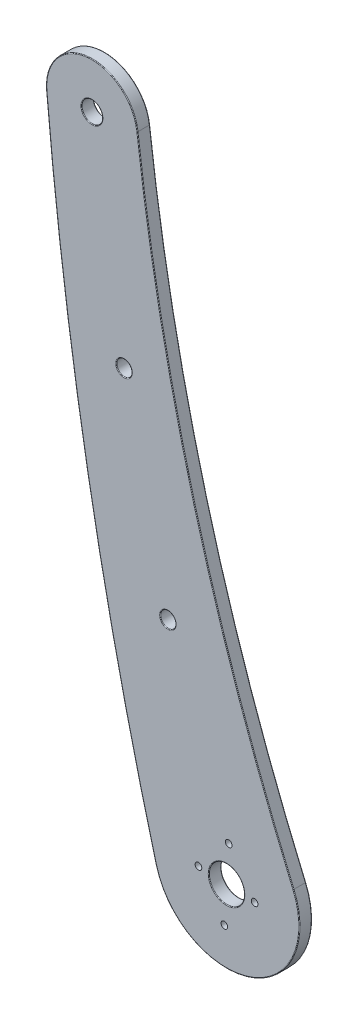
from build123d import *

# Parameters (mm, degrees)
SKETCH1_R              = 2.5
SKETCH1_R_2            = 4.25
BOSS_EXTRUDE1_DEPTH    = 3
M3_5_CLEARANCE_HOLE2_D = 3.7
FILLET1_R              = 0.15
SKETCH5_R              = 0.8
CUT_EXTRUDE1_DEPTH     = 10


with BuildPart() as part:
    # Sketch1 → Boss-Extrude1 (new body)
    with BuildSketch(Plane.XY):
        with BuildLine():
            ThreePointArc((-41.610876402, 203.318893996), (-27.897661437, 132.566736908), (-4.155361538, 64.520993523))
            ThreePointArc((-4.155361538, 64.520993523), (-14.44377014, 41.06076368), (-37.109507396, 52.998020086))
            ThreePointArc((-37.109507396, 52.998020086), (-53.580358622, 126.437133771), (-63.490331164, 201.045342457))
            ThreePointArc((-63.490331164, 201.045342457), (-53.669587691, 212.950626168), (-41.610876402, 203.318893996))
        make_face()
        with Locations((-52.532670476, 202.009537592)):
            Circle(SKETCH1_R, mode=Mode.SUBTRACT)
        with Locations((-20.22, 57.58)):
            Circle(SKETCH1_R_2, mode=Mode.SUBTRACT)
    extrude(amount=-BOSS_EXTRUDE1_DEPTH)

    # M3.5 Clearance Hole2 (through all)
    with Locations(Plane(origin=(0, 0, -3), x_dir=(-1, 0, 0), z_dir=(0, 0, -1))):
        with Locations((44.832747943, 152.605983135), (34.306162612, 105.554785282)):
            Hole(M3_5_CLEARANCE_HOLE2_D / 2)

    # Fillet1
    fillet1_edges = [part.edges().sort_by_distance(p)[0] for p in [
        (-55.032670476, 202.009537592, -3),
        (-55.032670476, 202.009537592, 0),
        (-14.44377014, 41.06076368, -3),
        (-24.47, 57.58, -3),
        (-24.47, 57.58, 0),
        (-27.897661437, 132.566736908, -3),
        (-36.156162612, 105.554785282, -3),
        (-36.156162612, 105.554785282, 0),
        (-46.682747943, 152.605983135, -3),
        (-46.682747943, 152.605983135, 0),
        (-53.669587691, 212.950626168, -3),
        (-27.897661437, 132.566736908, 0),
        (-14.44377014, 41.06076368, 0),
        (-53.580358622, 126.437133771, 0),
        (-53.669587691, 212.950626168, 0),
        (-53.580358622, 126.437133771, -3),
    ]]
    fillet(fillet1_edges, radius=FILLET1_R)

    # Sketch5 → Cut-Extrude1 (cut)
    with BuildSketch(Plane(origin=(0, 0, -3), x_dir=(-1, 0, 0), z_dir=(0, 0, -1))):
        with Locations((26.957856554, 57.984708606)):
            Circle(SKETCH5_R)
        with Locations((20.744622268, 48.845741504)):
            Circle(SKETCH5_R)
        with Locations((13.482143446, 57.175291394)):
            Circle(SKETCH5_R)
        with Locations((19.695377732, 66.314258496)):
            Circle(SKETCH5_R)
    extrude(amount=-CUT_EXTRUDE1_DEPTH, mode=Mode.SUBTRACT)


solid = part.part
